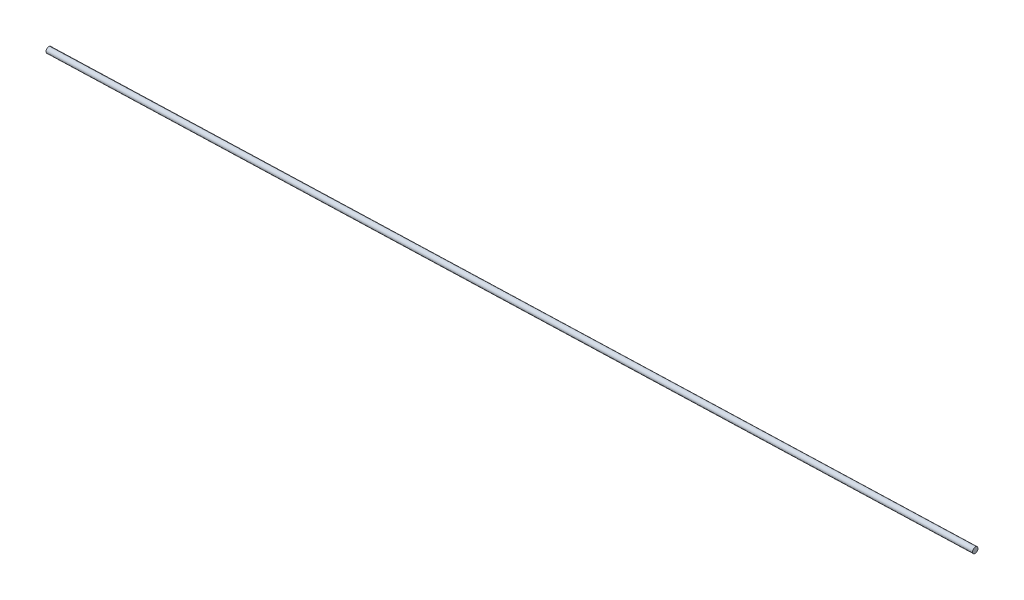
from build123d import *

# Parameters (mm, degrees)
SKETCH2_R           = 3.175
BOSS_EXTRUDE1_DEPTH = 1016


with BuildPart() as part:
    # Sketch2 → Boss-Extrude1 (new body)
    with BuildSketch(Plane(origin=(-1604.774268025, 0.505615361, 54.236286673), x_dir=(0.033777379, -0.000520585, 0.999429246), z_dir=(-0.999429326, 0.00031489, 0.033777545))):
        with Locations((2.159, 0)):
            Circle(SKETCH2_R)
    extrude(amount=BOSS_EXTRUDE1_DEPTH)


solid = part.part
